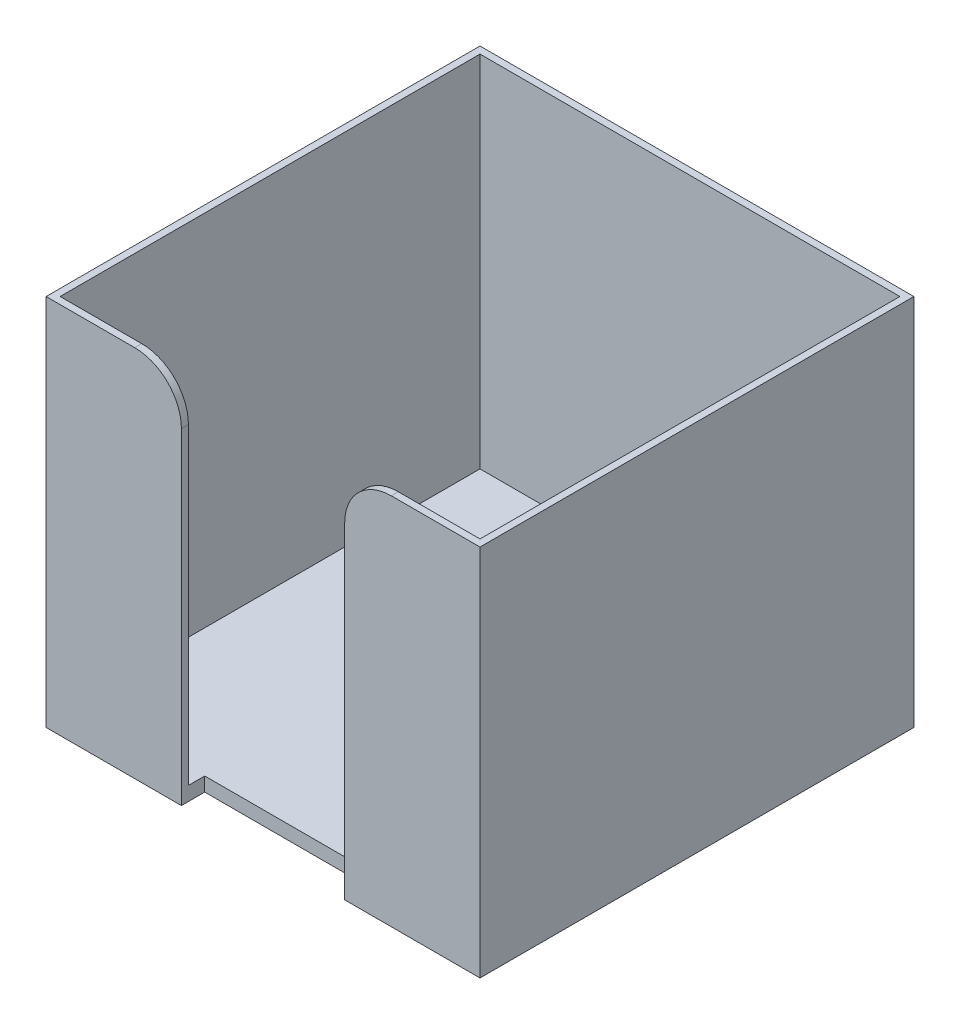
from build123d import *

# Parameters (mm, degrees)
SKETCH1_W           = 93
SKETCH1_H           = 93
BOSS_EXTRUDE1_DEPTH = 80
SKETCH3_W           = 90
SKETCH3_H           = 90
CUT_EXTRUDE1_DEPTH  = 77
SKETCH4_W           = 35
SKETCH4_H           = 80
CUT_EXTRUDE2_DEPTH  = 5
FILLET1_R           = 10


with BuildPart() as part:
    # Sketch1 → Boss-Extrude1 (new body)
    with BuildSketch(Plane(origin=(0, 0, 0), x_dir=(1, 0, 0), z_dir=(0, 1, 0))):
        Rectangle(SKETCH1_W, SKETCH1_H)
    extrude(amount=BOSS_EXTRUDE1_DEPTH)

    # Sketch3 → Cut-Extrude1 (cut)
    with BuildSketch(Plane(origin=(0, 80, 0), x_dir=(1, 0, 0), z_dir=(0, 1, 0))):
        Rectangle(SKETCH3_W, SKETCH3_H)
    extrude(amount=-CUT_EXTRUDE1_DEPTH, mode=Mode.SUBTRACT)

    # Sketch4 → Cut-Extrude2 (cut)
    with BuildSketch(Plane.XY.offset(46.5)):
        with Locations((0, 40)):
            Rectangle(SKETCH4_W, SKETCH4_H)
    extrude(amount=-CUT_EXTRUDE2_DEPTH, mode=Mode.SUBTRACT)

    # Fillet1
    fillet1_edges = [part.edges().sort_by_distance(p)[0] for p in [
        (-17.5, 80, 45.75),
        (17.5, 80, 45.75),
    ]]
    fillet(fillet1_edges, radius=FILLET1_R)


solid = part.part
